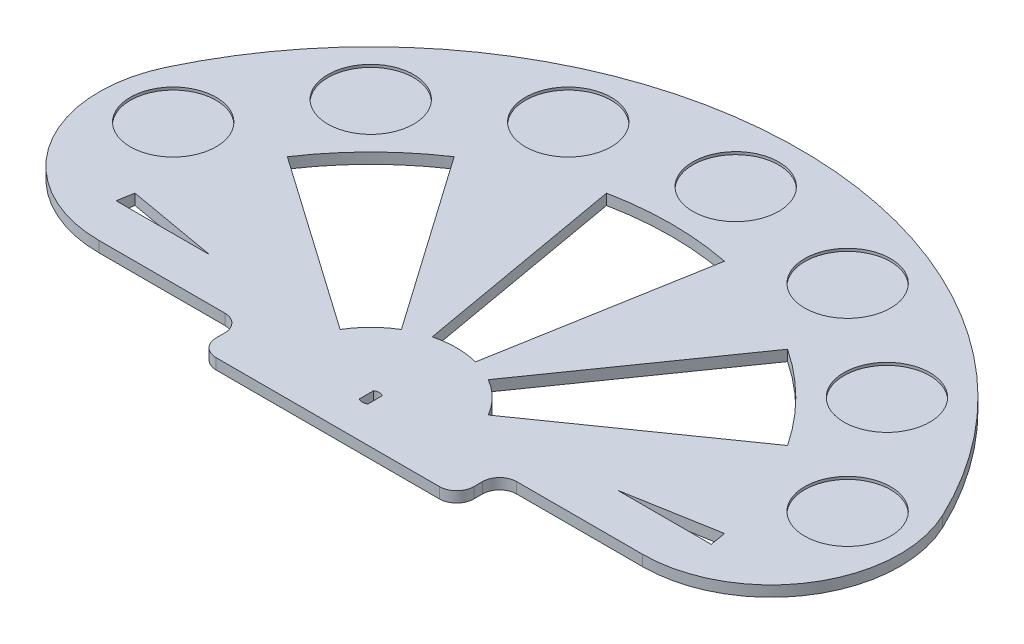
from build123d import *

# Parameters (mm, degrees)
BOSS_EXTRUDE1_DEPTH = 3.175
CUT_EXTRUDE4_START  = 3.175
SKETCH1_4_R         = 12.7
CUT_EXTRUDE4_DEPTH  = 0.79375


with BuildPart() as part:
    # Sketch1 → Boss-Extrude1 (new body)
    with BuildSketch(Plane(origin=(0, 0, 0), x_dir=(1, 0, 0), z_dir=(0, 1, 0))):
        with BuildLine():
            ThreePointArc((-88.894631333, 0.976995485), (-84.635987937, 0.245036838), (-80.321852568, 0))
            Line((-80.321852568, 0), (-43.18, 0))
            ThreePointArc((-43.18, 0), (-39.587897552, -1.487897552), (-38.1, -5.08))
            Line((-38.1, -5.08), (-38.1, -7.62))
            ThreePointArc((-38.1, -7.62), (-38.067046449, -8.197686885), (-37.968613332, -8.767878954))
            ThreePointArc((-37.968613332, -8.767878954), (-36.180314455, -11.597287083), (-33.02, -12.7))
            Line((-33.02, -12.7), (33.02, -12.7))
            ThreePointArc((33.02, -12.7), (36.180314455, -11.597287083), (37.968613332, -8.767878954))
            ThreePointArc((37.968613332, -8.767878954), (38.067046449, -8.197686885), (38.1, -7.62))
            Line((38.1, -7.62), (38.1, -5.08))
            ThreePointArc((38.1, -5.08), (39.587897552, -1.487897552), (43.18, 0))
            Line((43.18, 0), (80.321852568, 0))
            ThreePointArc((80.321852568, 0), (84.635987937, 0.245036838), (88.894631333, 0.976995485))
            ThreePointArc((88.894631333, 0.976995485), (114.6211381, 21.511780928), (114.745503669, 54.428571429))
            ThreePointArc((114.745503669, 54.428571429), (0, 127), (-114.745503669, 54.428571429))
            ThreePointArc((-114.745503669, 54.428571429), (-114.6211381, 21.511780928), (-88.894631333, 0.976995485))
        make_face()
        with BuildLine():
            Line((-60.268779933, 12.7), (-87.988181024, 12.7))
            ThreePointArc((-87.988181024, 12.7), (-87.612112441, 15.077392137), (-87.171820099, 17.443731844))
            Line((-87.171820099, 17.443731844), (-60.268779933, 12.7))
        make_face(mode=Mode.SUBTRACT)
        with BuildLine():
            Line((-1.28, -2.14746362), (-1.28, 2.14746362))
            ThreePointArc((-1.28, 2.14746362), (0, 2.5), (1.28, 2.14746362))
            Line((1.28, 2.14746362), (1.28, -2.14746362))
            ThreePointArc((1.28, -2.14746362), (0, -2.5), (-1.28, -2.14746362))
        make_face(mode=Mode.SUBTRACT)
        with BuildLine():
            ThreePointArc((87.171820099, 17.443731844), (87.612112441, 15.077392137), (87.988181024, 12.7))
            Line((87.988181024, 12.7), (60.268779933, 12.7))
            Line((60.268779933, 12.7), (87.171820099, 17.443731844))
        make_face(mode=Mode.SUBTRACT)
        with BuildLine():
            ThreePointArc((-73.974366197, 49.305204044), (-62.861792847, 62.861792847), (-49.305204044, 73.974366197))
            Line((-49.305204044, 73.974366197), (-12.849413735, 21.910101932))
            ThreePointArc((-12.849413735, 21.910101932), (-17.960512242, 17.960512242), (-21.910101932, 12.849413735))
            Line((-21.910101932, 12.849413735), (-73.974366197, 49.305204044))
        make_face(mode=Mode.SUBTRACT)
        with BuildLine():
            ThreePointArc((49.305204044, 73.974366197), (62.861792847, 62.861792847), (73.974366197, 49.305204044))
            Line((73.974366197, 49.305204044), (21.910101932, 12.849413735))
            ThreePointArc((21.910101932, 12.849413735), (17.960512242, 17.960512242), (12.849413735, 21.910101932))
            Line((12.849413735, 21.910101932), (49.305204044, 73.974366197))
        make_face(mode=Mode.SUBTRACT)
        with BuildLine():
            Line((-6.406874067, 24.578689239), (-17.443731844, 87.171820099))
            ThreePointArc((-17.443731844, 87.171820099), (0, 88.9), (17.443731844, 87.171820099))
            Line((17.443731844, 87.171820099), (6.406874067, 24.578689239))
            ThreePointArc((6.406874067, 24.578689239), (0, 25.4), (-6.406874067, 24.578689239))
        make_face(mode=Mode.SUBTRACT)
    extrude(amount=BOSS_EXTRUDE1_DEPTH)

    # Sketch1_4 → Cut-Extrude4 (cut)
    with BuildSketch(Plane(origin=(0, 0, 0), x_dir=(1, 0, 0), z_dir=(0, 1, 0)).offset(CUT_EXTRUDE4_START)):
        with Locations((-99.732795535, 41.310676524)):
            Circle(SKETCH1_4_R)
        with Locations((-76.332177029, 76.332177029)):
            Circle(SKETCH1_4_R)
        with Locations((-41.310676524, 99.732795535)):
            Circle(SKETCH1_4_R)
        with Locations((0, 107.95)):
            Circle(SKETCH1_4_R)
        with Locations((41.310676524, 99.732795535)):
            Circle(SKETCH1_4_R)
        with Locations((76.332177029, 76.332177029)):
            Circle(SKETCH1_4_R)
        with Locations((99.732795535, 41.310676524)):
            Circle(SKETCH1_4_R)
    extrude(amount=-CUT_EXTRUDE4_DEPTH, mode=Mode.SUBTRACT)


solid = part.part
